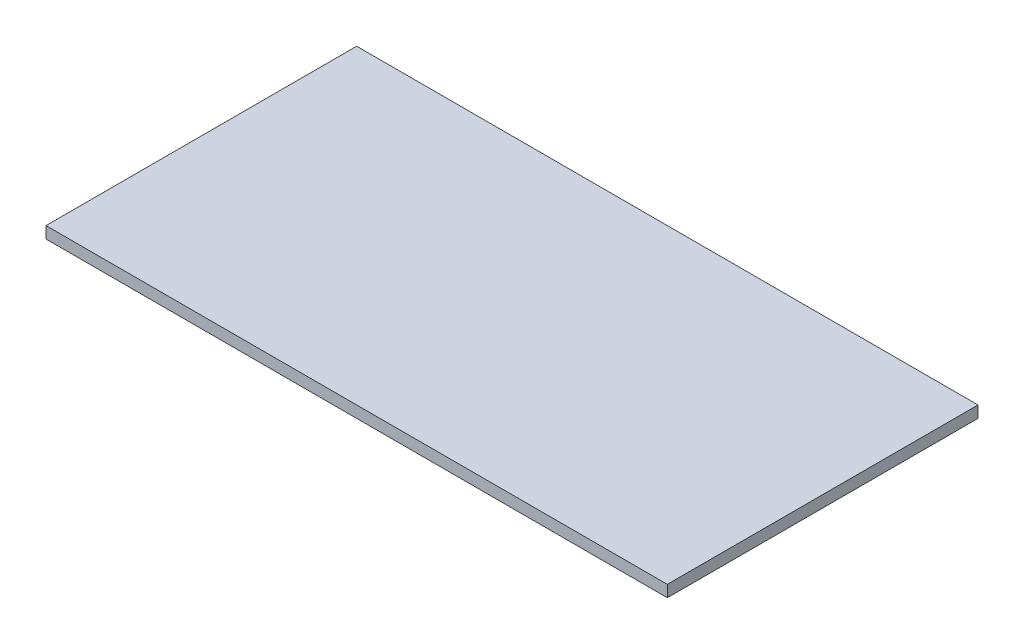
from build123d import *

# Parameters (mm, degrees)
SKETCH1_W           = 800
SKETCH1_H           = 400
BOSS_EXTRUDE1_DEPTH = 15


with BuildPart() as part:
    # Sketch1 → Boss-Extrude1 (new body)
    with BuildSketch(Plane(origin=(0, 0, 0), x_dir=(1, 0, 0), z_dir=(0, 1, 0))):
        with Locations((400, 200)):
            Rectangle(SKETCH1_W, SKETCH1_H)
    extrude(amount=BOSS_EXTRUDE1_DEPTH)


solid = part.part
